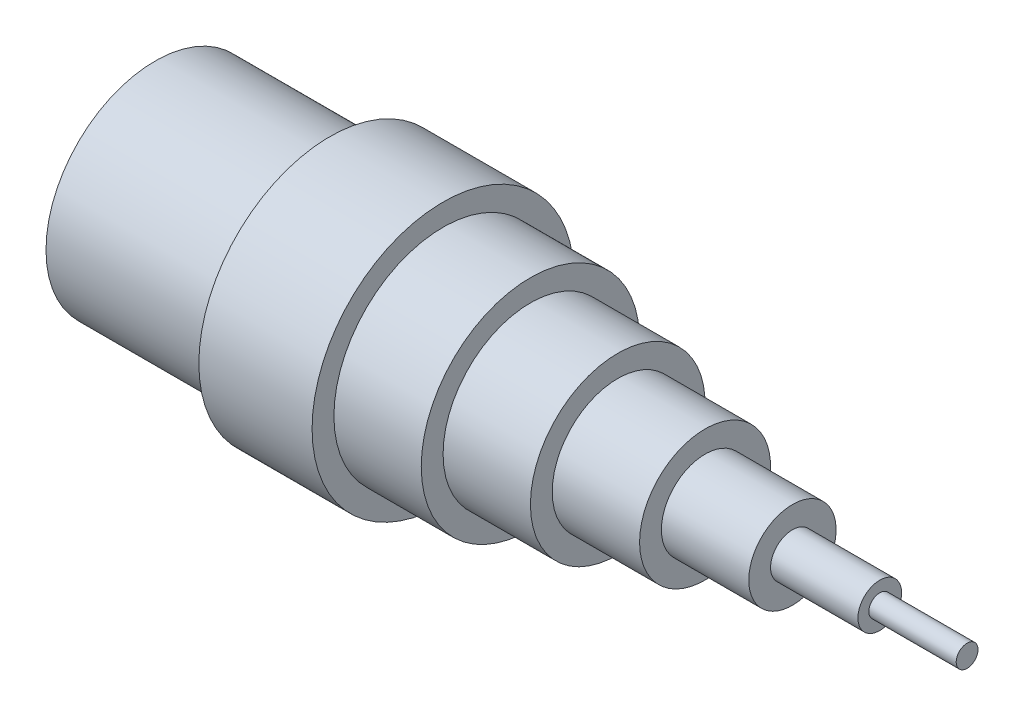
from build123d import *

# Parameters (mm, degrees)
SKETCH2_R          = 14.644408022
CUT_EXTRUDE1_DEPTH = 40


with BuildPart() as part:
    # Sketch1 → Revolve1 (revolve)
    with BuildSketch(Plane.XY, mode=Mode.PRIVATE) as revolve1_sk:
        Polygon((0, 0), (0, -25), (40, -25), (40, -30), (65.930548057, -30), (65.930548057, -25), (85.930548057, -25), (85.930548057, -20), (105.930548057, -20), (105.930548057, -15), (125.930548057, -15), (125.930548057, -10), (145.930548057, -10), (145.930548057, -5), (165.930548057, -5), (165.930548057, -2.5), (185.930548057, -2.5), (185.930548057, 0), align=None)
    revolve(revolve1_sk.sketch.rotate(Axis((0, 0, 0), (1, 0, 0)), 270), axis=Axis((0, 0, 0), (1, 0, 0)))  # turned: the seam where the file's is

    # Sketch2 → Cut-Extrude1 (cut)
    with BuildSketch(Plane.ZY):
        Circle(SKETCH2_R)
    extrude(amount=-CUT_EXTRUDE1_DEPTH, mode=Mode.SUBTRACT)


solid = part.part
